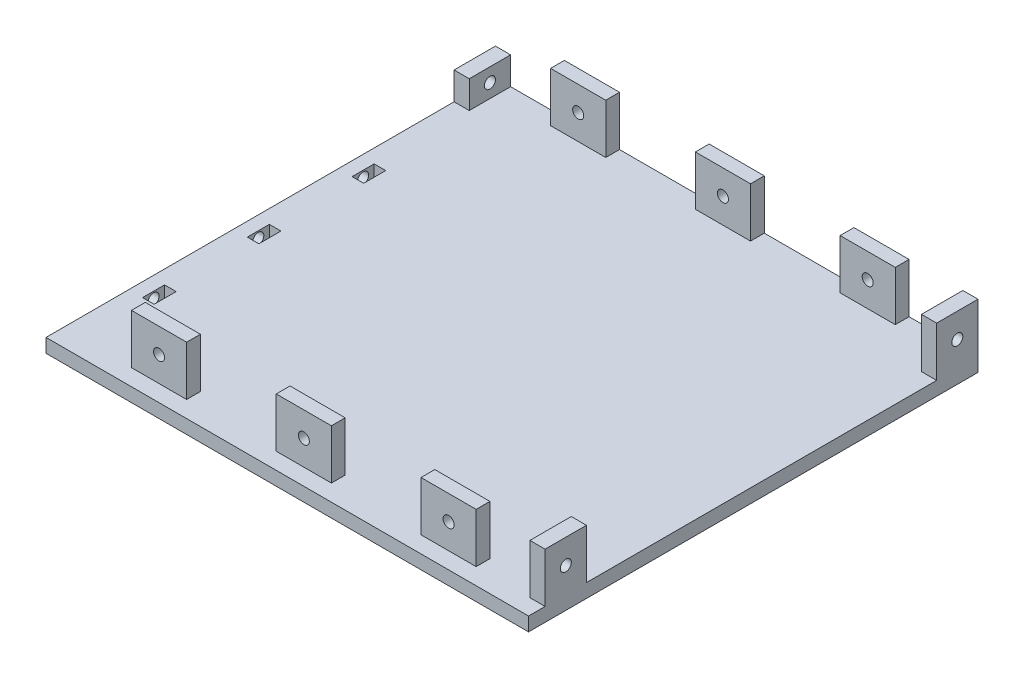
from build123d import *

# Parameters (mm, degrees)
SKETCH1_W               = 175
SKETCH1_H               = 163
BOSS_EXTRUDE1_DEPTH     = 5
SKETCH2_W               = 20
SKETCH2_H               = 5
BOSS_EXTRUDE2_DEPTH     = 18
SKETCH3_R               = 2
CUT_EXTRUDE1_DEPTH      = 7
CUT_EXTRUDE1_DEPTH_BACK = 158
SKETCH4_W               = 5.5
SKETCH4_H               = 15
BOSS_EXTRUDE3_DEPTH     = 18
SKETCH6_W               = 5.5
SKETCH6_H               = 15
BOSS_EXTRUDE4_DEPTH     = 10
SKETCH7_R               = 2
CUT_EXTRUDE3_DEPTH      = 10
SKETCH8_W               = 4.2
SKETCH8_H               = 8
CUT_EXTRUDE4_DEPTH      = 10
SKETCH9_R               = 2
CUT_EXTRUDE5_DEPTH      = 18
SKETCH5_R               = 2
CUT_EXTRUDE8_DEPTH      = 10


with BuildPart() as part:
    # Sketch1 → Boss-Extrude1 (new body)
    with BuildSketch(Plane(origin=(0, 0, 0), x_dir=(1, 0, 0), z_dir=(0, 1, 0))):
        with Locations((-64.046391753, -12.943298969)):
            Rectangle(SKETCH1_W, SKETCH1_H)
    extrude(amount=BOSS_EXTRUDE1_DEPTH)

    # Sketch2 → Boss-Extrude2 (add)
    with BuildSketch(Plane(origin=(0, 5, 0), x_dir=(1, 0, 0), z_dir=(0, 1, 0))):
        with Locations((-116.546391753, 66.056701031)):
            Rectangle(SKETCH2_W, SKETCH2_H)
        with Locations((-116.546391753, -85.943298969)):
            Rectangle(SKETCH2_W, SKETCH2_H)
        with Locations((-11.546391753, -85.943298969)):
            Rectangle(SKETCH2_W, SKETCH2_H)
        with Locations((-11.546391753, 66.056701031)):
            Rectangle(SKETCH2_W, SKETCH2_H)
        with Locations((-64.046391753, -85.943298969)):
            Rectangle(SKETCH2_W, SKETCH2_H)
        with Locations((-64.046391753, 66.056701031)):
            Rectangle(SKETCH2_W, SKETCH2_H)
    extrude(amount=BOSS_EXTRUDE2_DEPTH)

    # Sketch3 → Cut-Extrude1 (cut, two sides)
    with BuildSketch(Plane.XY.offset(88.443298969)) as cut_extrude1_sk:
        with Locations((-116.546391753, 14.1)):
            Circle(SKETCH3_R)
        with Locations((-64.046391753, 14.1)):
            Circle(SKETCH3_R)
        with Locations((-11.546391753, 14.1)):
            Circle(SKETCH3_R)
    extrude(amount=CUT_EXTRUDE1_DEPTH, mode=Mode.SUBTRACT)
    extrude(cut_extrude1_sk.sketch, amount=-CUT_EXTRUDE1_DEPTH_BACK, mode=Mode.SUBTRACT)

    # Sketch4 → Boss-Extrude3 (add)
    with BuildSketch(Plane(origin=(0, 5, 0), x_dir=(1, 0, 0), z_dir=(0, 1, 0))):
        with Locations((-148.796391753, 61.056701031)):
            Rectangle(SKETCH4_W, SKETCH4_H)
        with Locations((-148.796391753, -80.943298969)):
            Rectangle(SKETCH4_W, SKETCH4_H)
    extrude(amount=BOSS_EXTRUDE3_DEPTH)

    # Sketch6 → Boss-Extrude4 (add)
    with BuildSketch(Plane(origin=(0, 5, 0), x_dir=(1, 0, 0), z_dir=(0, 1, 0))):
        with Locations((20.703608247, 61.056701031)):
            Rectangle(SKETCH6_W, SKETCH6_H)
    extrude(amount=BOSS_EXTRUDE4_DEPTH)

    # Sketch7 → Cut-Extrude3 (cut)
    with BuildSketch(Plane(origin=(23.453608247, 0, 0), x_dir=(0, 0, -1), z_dir=(1, 0, 0))):
        with Locations((61.056701031, 10)):
            Circle(SKETCH7_R)
    extrude(amount=-CUT_EXTRUDE3_DEPTH, mode=Mode.SUBTRACT)

    # Sketch8 → Cut-Extrude4 (cut)
    with BuildSketch(Plane(origin=(0, 5, 0), x_dir=(1, 0, 0), z_dir=(0, 1, 0))):
        with Locations((16.353608247, -60.443298969)):
            Rectangle(SKETCH8_W, SKETCH8_H)
        with Locations((16.353608247, -22.443298969)):
            Rectangle(SKETCH8_W, SKETCH8_H)
        with Locations((16.353608247, 15.556701031)):
            Rectangle(SKETCH8_W, SKETCH8_H)
    extrude(amount=-CUT_EXTRUDE4_DEPTH, mode=Mode.SUBTRACT)

    # Sketch9 → Cut-Extrude5 (cut)
    with BuildSketch(Plane(origin=(23.453608247, 0, 0), x_dir=(0, 0, -1), z_dir=(1, 0, 0))):
        with Locations((-22.443298969, 2.5)):
            Circle(SKETCH9_R)
        with Locations((-60.443298969, 2.5)):
            Circle(SKETCH9_R)
        with Locations((15.556701031, 2.5)):
            Circle(SKETCH9_R)
    extrude(amount=-CUT_EXTRUDE5_DEPTH, mode=Mode.SUBTRACT)

    # Sketch5 → Cut-Extrude8 (cut)
    with BuildSketch(Plane(origin=(-146.046391753, 0, 0), x_dir=(0, 0, -1), z_dir=(1, 0, 0))):
        with Locations((61.056701031, 14.1)):
            Circle(SKETCH5_R)
        with Locations((-80.943298969, 14.1)):
            Circle(SKETCH5_R)
    extrude(amount=-CUT_EXTRUDE8_DEPTH, mode=Mode.SUBTRACT)


with BuildPart() as body_2:
    # Mirror3: mirrored copy
    add(part.part.mirror(Plane(origin=(-151.546391753, 5, -68.556701031), x_dir=(0, 0, 1), z_dir=(1, 0, 0))))


solid = body_2.part
